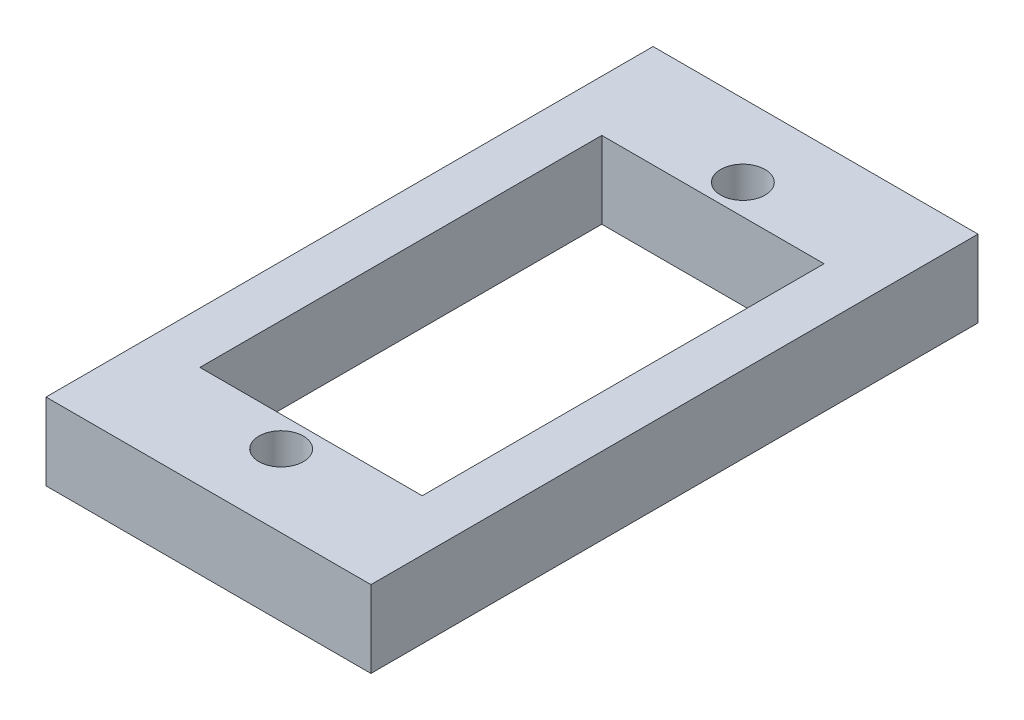
from build123d import *

# Parameters (mm, degrees)
SKETCH1_W           = 19
SKETCH1_H           = 35.5
SKETCH1_R           = 1.3
SKETCH1_W_2         = 13
SKETCH1_H_2         = 23.5
BOSS_EXTRUDE1_DEPTH = 4.5


with BuildPart() as part:
    # Sketch1 → Boss-Extrude1 (new body)
    with BuildSketch(Plane(origin=(0, 0, 0), x_dir=(1, 0, 0), z_dir=(0, 1, 0))):
        Rectangle(SKETCH1_W, SKETCH1_H)
        with Locations((0, 13.5)):
            Circle(SKETCH1_R, mode=Mode.SUBTRACT)
        with Locations((0, -13.5)):
            Circle(SKETCH1_R, mode=Mode.SUBTRACT)
        Rectangle(SKETCH1_W_2, SKETCH1_H_2, mode=Mode.SUBTRACT)
    extrude(amount=BOSS_EXTRUDE1_DEPTH)


solid = part.part
